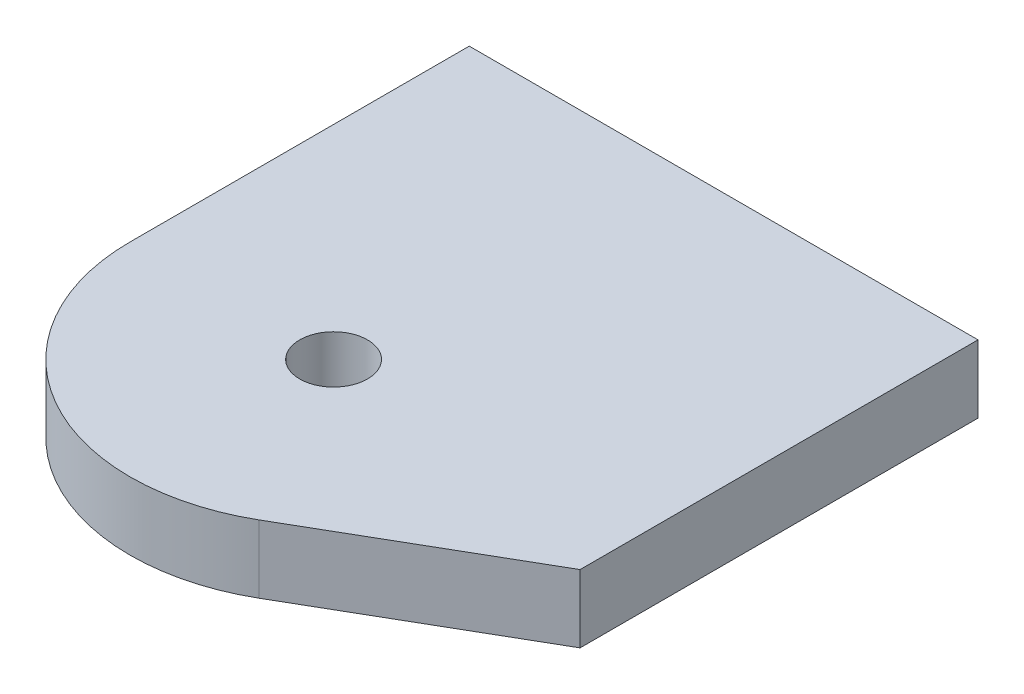
from build123d import *

# Parameters (mm, degrees)
ESQUISSE1_R        = 1
BOSS_EXTRU_1_DEPTH = 2


with BuildPart() as part:
    # Esquisse1 → Boss.-Extru.1 (new body)
    with BuildSketch(Plane(origin=(0, 0, 0), x_dir=(1, 0, 0), z_dir=(0, 1, 0))):
        with BuildLine():
            Line((-6, 0), (-6, 10))
            Line((-6, 10), (9, 10))
            Line((9, 10), (9, -1.732050808))
            Line((9, -1.732050808), (3, -5.196152423))
            ThreePointArc((3, -5.196152423), (-3, -5.196152423), (-6, 0))
        make_face()
        Circle(ESQUISSE1_R, mode=Mode.SUBTRACT)
    extrude(amount=BOSS_EXTRU_1_DEPTH)


solid = part.part
